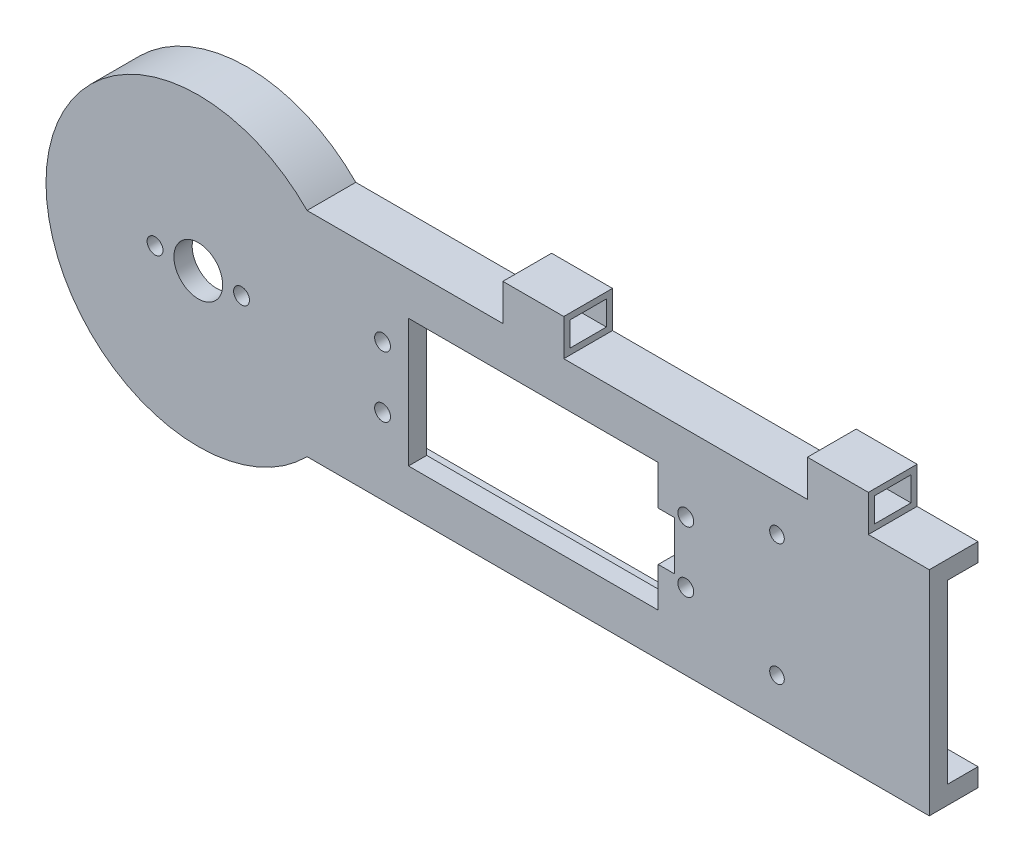
from build123d import *

# Parameters (mm, degrees)
DODANIE_WYCI_GNI_CIE1_DEPTH = 8
OTW_R_POD_RUB_M22_D         = 2.6
SKORUPA1_T                  = -3
DODANIE_WYCI_GNI_CIE2_REACH = 228.526
OTW_R_POD_RUB_M21_D         = 2.6
WYTNIJ_WYCI_GNI_CIE1_REACH  = 228.526
SZKIC7_W                    = 41
SZKIC7_H                    = 21
OTWORY_USTALAJ_CE_8_0MM1_D  = 8
OTW_R_POD_RUB_M23_D         = 2.6
WYTNIJ_WYCI_GNI_CIE2_REACH  = 228.526
SZKIC13_W                   = 5.14
SZKIC13_H                   = 8
SZKIC18_W                   = 8
SZKIC18_H                   = 6
SZKIC18_W_2                 = 6
SZKIC18_H_2                 = 4
DODANIE_WYCI_GNI_CIE3_DEPTH = 10
SZYK_LINIOWY1_COUNT         = 2
SZYK_LINIOWY1_PITCH         = 50
OTW_R_POD_RUB_M24_D         = 2.4


with BuildPart() as part:
    # Szkic1 → Dodanie-wyciągnięcie1 (new body)
    with BuildSketch(Plane.XY):
        with BuildLine():
            Line((17.853571071, 17.5), (182.146428929, 17.5))
            ThreePointArc((182.146428929, 17.5), (225, 0), (182.146428929, -17.5))
            Line((182.146428929, -17.5), (17.853571071, -17.5))
            ThreePointArc((17.853571071, -17.5), (-25, 0), (17.853571071, 17.5))
        make_face()
    extrude(amount=DODANIE_WYCI_GNI_CIE1_DEPTH)

    # Otwór pod śrubę M22 (through all)
    with Locations(Plane(origin=(0, 0, 8), x_dir=(-1, 0, 0), z_dir=(0, 0, 1))):
        with Locations((-200, 0)):
            Hole(OTW_R_POD_RUB_M22_D / 2)

    # Skorupa1
    skorupa1_openings = [part.faces().sort_by_distance(p)[0] for p in [
        (99.943079522, 0, 0),
    ]]
    offset(amount=SKORUPA1_T, openings=skorupa1_openings, kind=Kind.INTERSECTION)

    # Szkic15 → Dodanie-wyciągnięcie2 (add, up to next)
    with BuildSketch(Plane(origin=(0, 0, 0), x_dir=(-1, 0, 0), z_dir=(0, 0, -1)), mode=Mode.PRIVATE) as dodanie_wyci_gni_cie2_sk1:
        with BuildLine():
            Line((-16.545392108, -14.5), (-19.124591499, -14.5))
            ThreePointArc((-19.124591499, -14.5), (-24, 0), (-19.124591499, 14.5))
            Line((-19.124591499, 14.5), (-16.545392108, 14.5))
            ThreePointArc((-16.545392108, 14.5), (-22, 0), (-16.545392108, -14.5))
        make_face()
    dodanie_wyci_gni_cie2_tool1 = extrude(dodanie_wyci_gni_cie2_sk1.sketch, amount=-DODANIE_WYCI_GNI_CIE2_REACH, mode=Mode.PRIVATE) - part.part
    # Szkic15 → Dodanie-wyciągnięcie2 (add, up to next)
    with BuildSketch(Plane(origin=(0, 0, 0), x_dir=(-1, 0, 0), z_dir=(0, 0, -1)), mode=Mode.PRIVATE) as dodanie_wyci_gni_cie2_sk2:
        with BuildLine():
            Line((-180.875408501, -14.5), (-183.454607892, -14.5))
            ThreePointArc((-183.454607892, -14.5), (-178, 0), (-183.454607892, 14.5))
            Line((-183.454607892, 14.5), (-180.875408501, 14.5))
            ThreePointArc((-180.875408501, 14.5), (-176, 0), (-180.875408501, -14.5))
        make_face()
    dodanie_wyci_gni_cie2_tool2 = extrude(dodanie_wyci_gni_cie2_sk2.sketch, amount=-DODANIE_WYCI_GNI_CIE2_REACH, mode=Mode.PRIVATE) - part.part
    add(dodanie_wyci_gni_cie2_tool1.solids().sort_by_distance((17.834992, 14.200572, 0))[0])
    add(dodanie_wyci_gni_cie2_tool2.solids().sort_by_distance((182.165008, -14.200572, 0))[0])

    # Otwór pod śrubę M21 (through all)
    with Locations(Plane.XY.offset(8)):
        with Locations((7.1, 0), (-7.1, 0)):
            Hole(OTW_R_POD_RUB_M21_D / 2)

    # Szkic7 → Wytnij-wyciągnięcie1 (cut, up to next)
    with BuildSketch(Plane(origin=(0, 0, 0), x_dir=(-1, 0, 0), z_dir=(0, 0, -1)), mode=Mode.PRIVATE) as wytnij_wyci_gni_cie1_sk1:
        with Locations((-55, 0)):
            Rectangle(SZKIC7_W, SZKIC7_H)
    wytnij_wyci_gni_cie1_tool1 = extrude(wytnij_wyci_gni_cie1_sk1.sketch, amount=-WYTNIJ_WYCI_GNI_CIE1_REACH, mode=Mode.PRIVATE) & part.part
    add(wytnij_wyci_gni_cie1_tool1.solids().sort_by_distance((55, 0, 0))[0], mode=Mode.SUBTRACT)

    # Otwory ustalające Ø8.0mm1 (through all)
    with Locations(Plane(origin=(0, 0, 8), x_dir=(-1, 0, 0), z_dir=(0, 0, 1))):
        with Locations((0, 0)):
            Hole(OTWORY_USTALAJ_CE_8_0MM1_D / 2)

    # Otwór pod śrubę M23 (through all)
    with Locations(Plane(origin=(0, 0, 8), x_dir=(-1, 0, 0), z_dir=(0, 0, 1))):
        with Locations((-80.03, 5), (-80.03, -5), (-30.25, -5), (-30.25, 5)):
            Hole(OTW_R_POD_RUB_M23_D / 2)

    # Szkic13 → Wytnij-wyciągnięcie2 (cut, up to next)
    with BuildSketch(Plane(origin=(0, 0, 0), x_dir=(-1, 0, 0), z_dir=(0, 0, -1)), mode=Mode.PRIVATE) as wytnij_wyci_gni_cie2_sk1:
        with Locations((-75.57, 0)):
            Rectangle(SZKIC13_W, SZKIC13_H)
    wytnij_wyci_gni_cie2_tool1 = extrude(wytnij_wyci_gni_cie2_sk1.sketch, amount=-WYTNIJ_WYCI_GNI_CIE2_REACH, mode=Mode.PRIVATE) & part.part
    add(wytnij_wyci_gni_cie2_tool1.solids().sort_by_distance((75.57, 0, 0))[0], mode=Mode.SUBTRACT)

    # Szkic18 → Dodanie-wyciągnięcie3 (add)
    with BuildSketch(Plane(origin=(50, 0, 0), x_dir=(0, 0, -1), z_dir=(1, 0, 0))):
        with Locations((-4, 20.5)):
            Rectangle(SZKIC18_W, SZKIC18_H)
        with Locations((-4, 20.5)):
            Rectangle(SZKIC18_W_2, SZKIC18_H_2, mode=Mode.SUBTRACT)
    dodanie_wyci_gni_cie3 = extrude(amount=DODANIE_WYCI_GNI_CIE3_DEPTH)

    # Szyk liniowy1: Dodanie-wyciągnięcie3 ×2
    with Locations(*[(i * SZYK_LINIOWY1_PITCH, 0, 0) for i in range(1, SZYK_LINIOWY1_COUNT)]):
        add(dodanie_wyci_gni_cie3)

    # Otwór pod śrubę M24 (through all)
    with Locations(Plane(origin=(0, 0, 5), x_dir=(-1, 0, 0), z_dir=(0, 0, -1))):
        with Locations((-145, -10), (-145, 10), (-95, 10), (-95, -10)):
            Hole(OTW_R_POD_RUB_M24_D / 2)

    # Cięcie powierzchnią1
    split(bisect_by=Plane(origin=(120, 0, 0), x_dir=(0, 0, -1), z_dir=(1, 0, 0)), keep=Keep.BOTTOM)


solid = part.part
